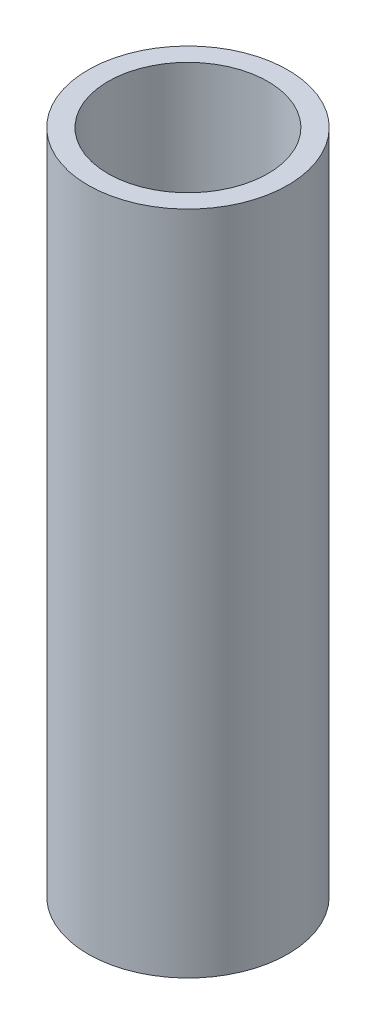
from build123d import *

# Parameters (mm, degrees)
SKETCH1_R           = 15
SKETCH1_R_2         = 12
BOSS_EXTRUDE1_DEPTH = 100


with BuildPart() as part:
    # Sketch1 → Boss-Extrude1 (new body)
    with BuildSketch(Plane(origin=(0, 0, 0), x_dir=(1, 0, 0), z_dir=(0, 1, 0))):
        Circle(SKETCH1_R)
        Circle(SKETCH1_R_2, mode=Mode.SUBTRACT)
    extrude(amount=BOSS_EXTRUDE1_DEPTH)


solid = part.part
